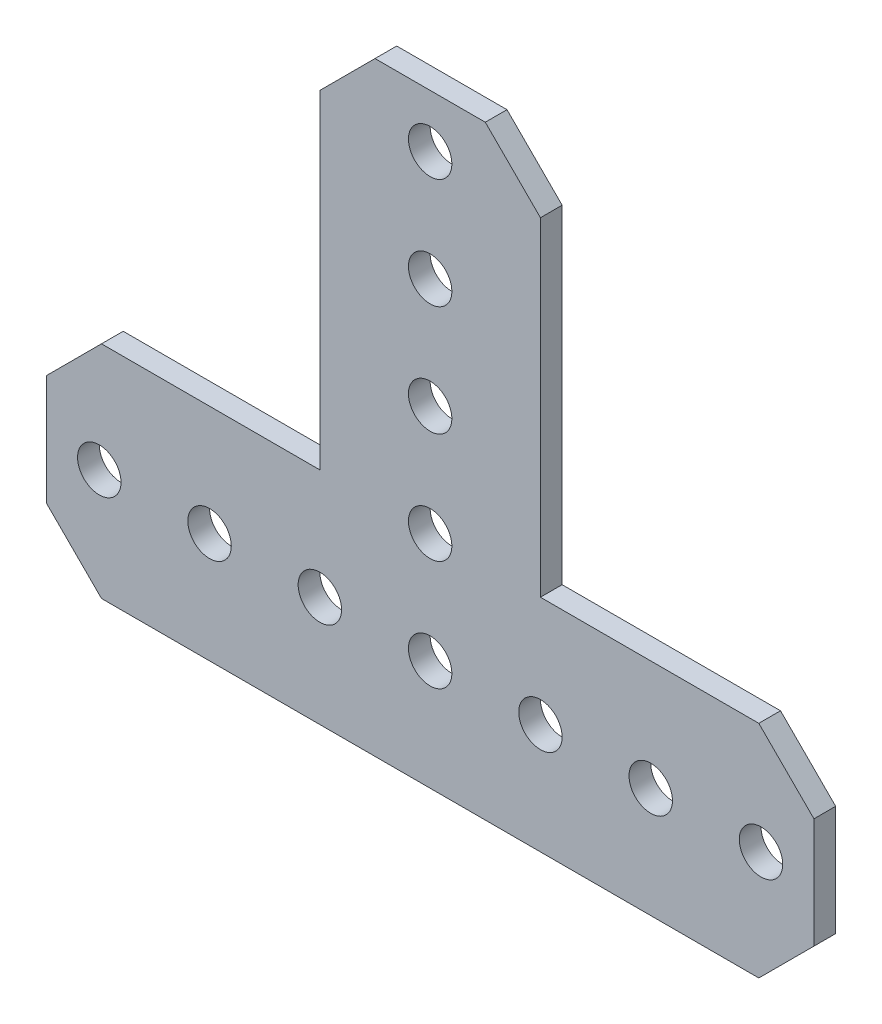
from build123d import *

# Parameters (mm, degrees)
SKETCH1_R           = 2.5
BOSS_EXTRUDE1_DEPTH = 2.5


with BuildPart() as part:
    # Sketch1 → Boss-Extrude1 (new body)
    with BuildSketch(Plane(origin=(0, 0, -1.25), x_dir=(-1, 0, 0), z_dir=(0, 0, -1))):
        Polygon((12.7, 12.7), (12.7, 50.546), (6.35, 56.896), (-6.35, 56.896), (-12.7, 50.546), (-12.7, 12.7), (-37.846, 12.7), (-44.196, 6.35), (-44.196, -6.35), (-37.846, -12.7), (37.846, -12.7), (44.196, -6.35), (44.196, 6.35), (37.846, 12.7), align=None)
        with Locations((0, 50.8)):
            Circle(SKETCH1_R, mode=Mode.SUBTRACT)
        with Locations((0, 38.1)):
            Circle(SKETCH1_R, mode=Mode.SUBTRACT)
        with Locations((-38.1, 0)):
            Circle(SKETCH1_R, mode=Mode.SUBTRACT)
        with Locations((-25.4, 0)):
            Circle(SKETCH1_R, mode=Mode.SUBTRACT)
        with Locations((-12.7, 0)):
            Circle(SKETCH1_R, mode=Mode.SUBTRACT)
        Circle(SKETCH1_R, mode=Mode.SUBTRACT)
        with Locations((12.7, 0)):
            Circle(SKETCH1_R, mode=Mode.SUBTRACT)
        with Locations((38.1, 0)):
            Circle(SKETCH1_R, mode=Mode.SUBTRACT)
        with Locations((25.4, 0)):
            Circle(SKETCH1_R, mode=Mode.SUBTRACT)
        with Locations((0, 12.7)):
            Circle(SKETCH1_R, mode=Mode.SUBTRACT)
        with Locations((0, 25.4)):
            Circle(SKETCH1_R, mode=Mode.SUBTRACT)
    extrude(amount=-BOSS_EXTRUDE1_DEPTH)


solid = part.part
